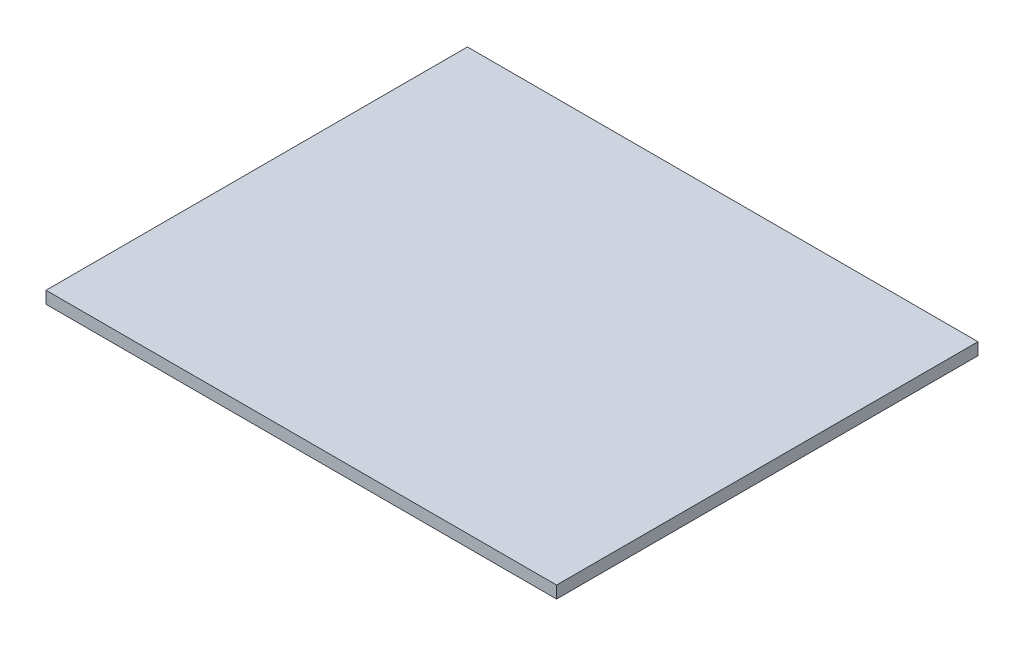
from build123d import *

# Parameters (mm, degrees)
SKETCH1_W           = 200.025
SKETCH1_H           = 165.1
BOSS_EXTRUDE1_DEPTH = 4.7625


with BuildPart() as part:
    # Sketch1 → Boss-Extrude1 (new body)
    with BuildSketch(Plane(origin=(0, 0, 0), x_dir=(1, 0, 0), z_dir=(0, 1, 0))):
        with Locations((100.0125, -82.55)):
            Rectangle(SKETCH1_W, SKETCH1_H)
    extrude(amount=BOSS_EXTRUDE1_DEPTH)


solid = part.part
